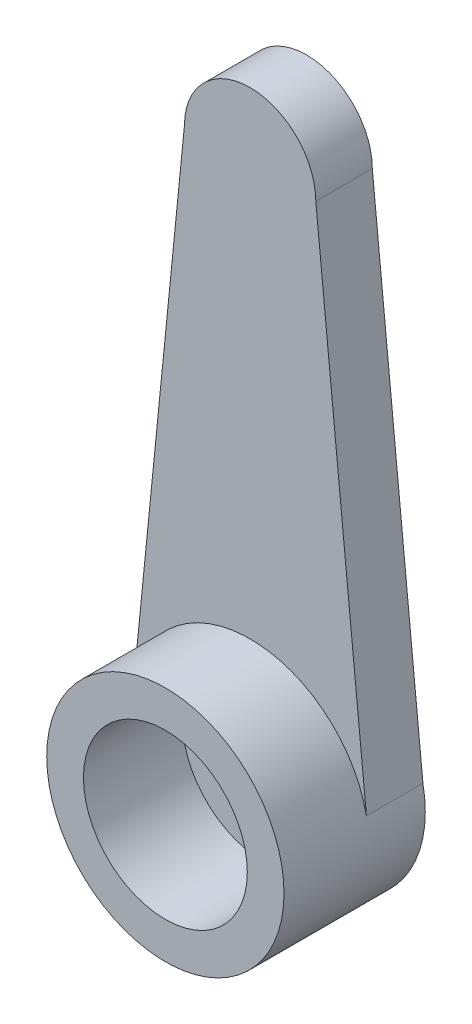
from build123d import *

# Parameters (mm, degrees)
BOSS_EXTRUDE1_DEPTH = 2
SKETCH1_3_R         = 2.9
BOSS_EXTRUDE2_DEPTH = 5
SKETCH1_4_R         = 2.9
SKETCH1_4_R_2       = 1.5
BOSS_EXTRUDE3_DEPTH = 1.5


with BuildPart() as part:
    # Sketch1 → Boss-Extrude1 (new body)
    with BuildSketch(Plane.XY):
        with BuildLine():
            ThreePointArc((-4.117050837, 0.83059762), (0, 4.2), (4.117050837, 0.83059762))
            Line((4.117050837, 0.83059762), (2.325, 18.775))
            ThreePointArc((2.325, 18.775), (0, 21.1), (-2.325, 18.775))
            Line((-2.325, 18.775), (-4.117050837, 0.83059762))
        make_face()
    extrude(amount=BOSS_EXTRUDE1_DEPTH)

    # Sketch1_3 → Boss-Extrude2 (add)
    with BuildSketch(Plane.XY):
        with BuildLine():
            ThreePointArc((4.2, 0), (4.17921126, 0.41736464), (4.117050837, 0.83059762))
            ThreePointArc((4.117050837, 0.83059762), (0, 4.2), (-4.117050837, 0.83059762))
            ThreePointArc((-4.117050837, 0.83059762), (-0.41736464, -4.17921126), (4.2, 0))
        make_face()
        Circle(SKETCH1_3_R, mode=Mode.SUBTRACT)
    extrude(amount=BOSS_EXTRUDE2_DEPTH)

    # Sketch1_4 → Boss-Extrude3 (add)
    with BuildSketch(Plane.XY):
        Circle(SKETCH1_4_R)
        Circle(SKETCH1_4_R_2, mode=Mode.SUBTRACT)
    extrude(amount=BOSS_EXTRUDE3_DEPTH)


solid = part.part
